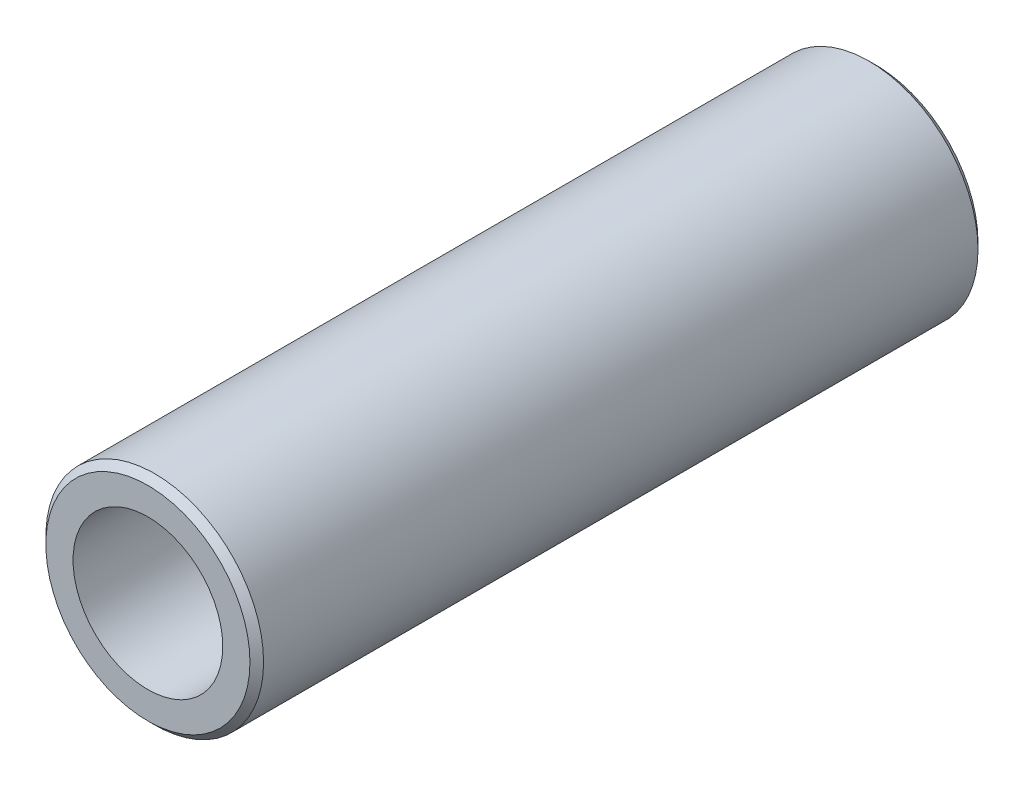
from build123d import *

# Parameters (mm, degrees)
SKETCH1_R           = 8
SKETCH1_R_2         = 5.5
BOSS_EXTRUDE1_DEPTH = 26.75
CHAMFER1_SIZE       = 0.5


with BuildPart() as part:
    # Sketch1 → Boss-Extrude1 (new body, symmetric)
    with BuildSketch(Plane.XY):
        Circle(SKETCH1_R)
        Circle(SKETCH1_R_2, mode=Mode.SUBTRACT)
    extrude(amount=BOSS_EXTRUDE1_DEPTH, both=True)

    # Chamfer1
    chamfer1_edges = [part.edges().sort_by_distance(p)[0] for p in [
        (-8, 0, -26.75),
        (-8, 0, 26.75),
    ]]
    chamfer(chamfer1_edges, length=CHAMFER1_SIZE)


solid = part.part
